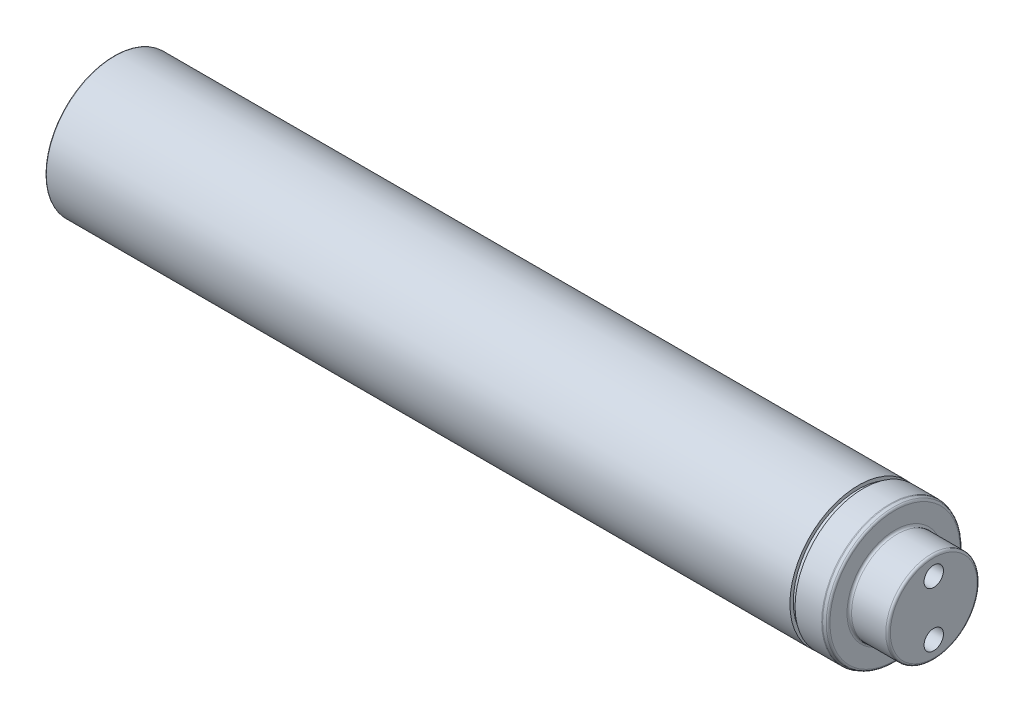
from build123d import *

# Parameters (mm, degrees)
HOLE2_D     = 8.5
HOLE2_DEPTH = 20
HOLE2_TIP   = 2.553657631


with BuildPart() as part:
    # Sketch1 → Base-Revolve (revolve)
    with BuildSketch(Plane.XY):
        with BuildLine():
            Line((163, 30), (0, 30))
            Line((0, 30), (-162.6, 30))
            ThreePointArc((-162.6, 30), (-162.882842712, 29.882842712), (-163, 29.6))
            Line((-163, 29.6), (-163, 28.4))
            ThreePointArc((-163, 28.4), (-163.117157288, 28.117157288), (-163.4, 28))
            Line((-163.4, 28), (-164, 28))
            Line((-164, 28), (-164, 25.230940108))
            ThreePointArc((-164, 25.230940108), (-164.053589838, 25.030940108), (-164.2, 24.884529946))
            Line((-164.2, 24.884529946), (-167.8, 22.806068977))
            ThreePointArc((-167.8, 22.806068977), (-167.946410162, 22.659658816), (-168, 22.459658816))
            Line((-168, 22.459658816), (-168, 5.1))
            Line((-168, 5.1), (-148, 5.1))
            Line((-148, 5.1), (-145.055513627, 0))
            Line((-145.055513627, 0), (196, 0))
            Line((196, 0), (196, 19))
            ThreePointArc((196, 19), (195.707106781, 19.707106781), (195, 20))
            Line((195, 20), (180, 20))
            ThreePointArc((180, 20), (179.292893219, 20.292893219), (179, 21))
            Line((179, 21), (179, 28.471851993))
            ThreePointArc((179, 28.471851993), (178.819152044, 29.04542843), (178.342020143, 29.411544614))
            Line((178.342020143, 29.411544614), (177.165693163, 29.839692621))
            ThreePointArc((177.165693163, 29.839692621), (176.997321197, 29.884807753), (176.823673019, 29.9))
            Line((176.823673019, 29.9), (165.15, 29.9))
            Line((165.15, 29.9), (165.15, 28.5))
            Line((165.15, 28.5), (163, 28.5))
            Line((163, 28.5), (163, 30))
        make_face()
    revolve(axis=Axis((-168, 0, 0), (1, 0, 0)))

    # Hole2
    with Locations(Plane(origin=(196, 0, 0), x_dir=(0, 0, -1), z_dir=(1, 0, 0))):
        with Locations((0, 12), (0, -12)):
            Hole(HOLE2_D / 2, depth=HOLE2_DEPTH)
            with Locations((0, 0, -(HOLE2_DEPTH + HOLE2_TIP / 2))):  # 118° drill point
                Cone(0, HOLE2_D / 2, HOLE2_TIP, mode=Mode.SUBTRACT)


solid = part.part
